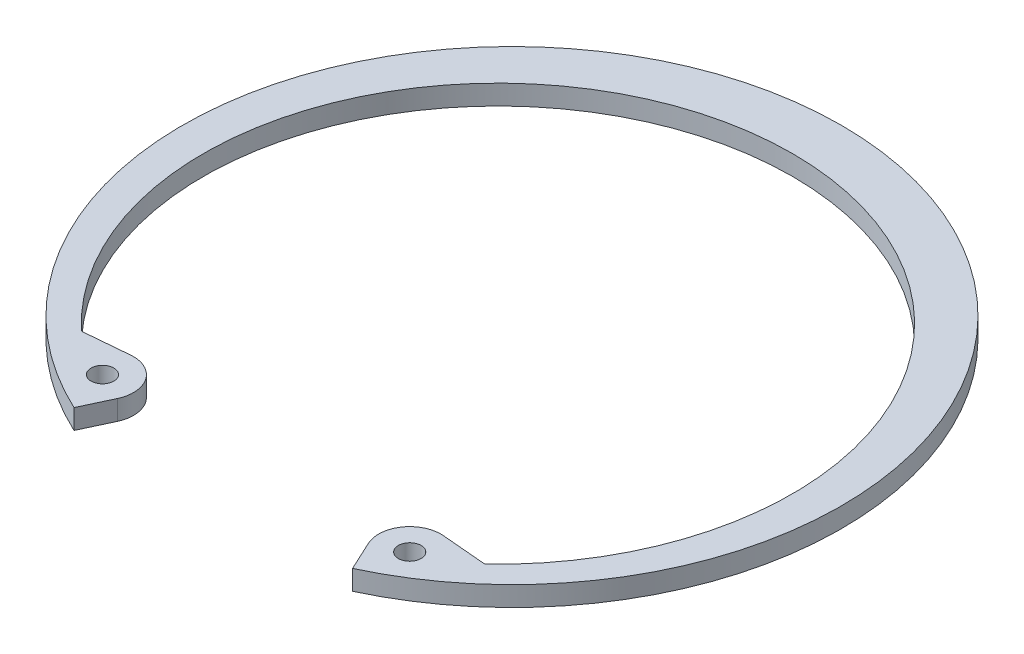
from build123d import *

# Parameters (mm, degrees)
SKETCH2_R      = 1.5875
EXTRUDE1_DEPTH = 2.7686
FILLET1_R      = 0.254


with BuildPart() as part:
    # Sketch2 → Extrude1 (new body)
    with BuildSketch(Plane(origin=(0, 0, 0), x_dir=(1, 0, 0), z_dir=(0, 1, 0))):
        with BuildLine():
            Line((19.445553721, -41.701124528), (17.514023997, -37.558945667))
            ThreePointArc((17.514023997, -37.558945667), (17.89257625, -33.232073615), (21.829033492, -31.396473457))
            Line((21.829033492, -31.396473457), (28.152071759, -31.949667624))
            ThreePointArc((28.152071759, -31.949667624), (0, 39.1795), (-28.152071759, -31.949667624))
            Line((-28.152071759, -31.949667624), (-21.829033492, -31.396473457))
            ThreePointArc((-21.829033492, -31.396473457), (-17.89257625, -33.232073615), (-17.514023997, -37.558945667))
            Line((-17.514023997, -37.558945667), (-19.445553721, -41.701124528))
            ThreePointArc((-19.445553721, -41.701124528), (0, 46.0121), (19.445553721, -41.701124528))
        make_face()
        with Locations((21.450481239, -35.723345508)):
            Circle(SKETCH2_R, mode=Mode.SUBTRACT)
        with Locations((-21.450481239, -35.723345508)):
            Circle(SKETCH2_R, mode=Mode.SUBTRACT)
    extrude(amount=-EXTRUDE1_DEPTH)

    # Fillet1
    fillet1_edges = [part.edges().sort_by_distance(p)[0] for p in [
        (28.152071759, -1.3843, 31.949667624),
        (-28.152071759, -1.3843, 31.949667624),
    ]]
    fillet(fillet1_edges, radius=FILLET1_R)


solid = part.part
